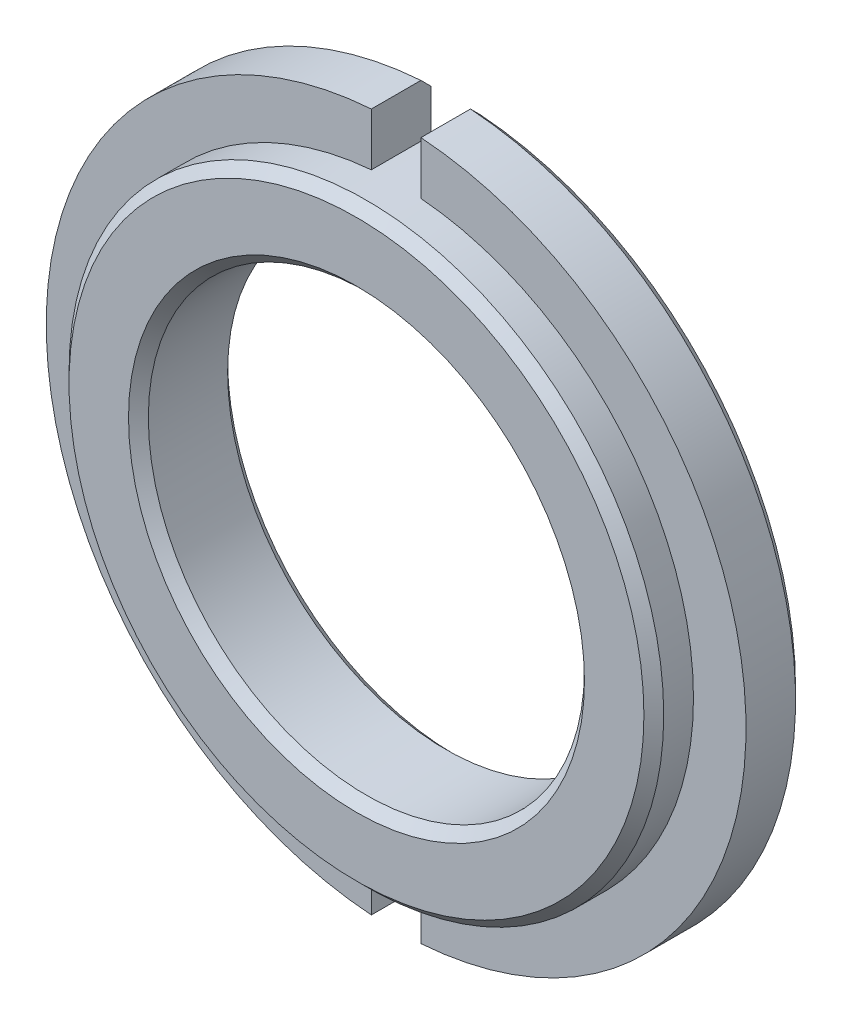
from build123d import *

# Parameters (mm, degrees)
SKETCH1_R           = 17.65
SKETCH1_R_2         = 11
BOSS_EXTRUDE1_DEPTH = 5
SKETCH2_R           = 17.65
SKETCH2_R_2         = 15
CUT_EXTRUDE1_DEPTH  = 2
CUT_EXTRUDE3_REACH  = 5
CHAMFER1_SIZE       = 0.5


with BuildPart() as part:
    # Sketch1 → Boss-Extrude1 (new body)
    with BuildSketch(Plane.XY):
        Circle(SKETCH1_R)
        Circle(SKETCH1_R_2, mode=Mode.SUBTRACT)
    extrude(amount=BOSS_EXTRUDE1_DEPTH)

    # Sketch2 → Cut-Extrude1 (cut)
    with BuildSketch(Plane.XY.offset(5)):
        Circle(SKETCH2_R)
        Circle(SKETCH2_R_2, mode=Mode.SUBTRACT)
    extrude(amount=-CUT_EXTRUDE1_DEPTH, mode=Mode.SUBTRACT)

    # Sketch3 → Cut-Extrude3 (cut, up to next)
    with BuildSketch(Plane.XY.offset(3), mode=Mode.PRIVATE) as cut_extrude3_sk1:
        with BuildLine():
            Line((1.25, 17.605680901), (1.25, 14.947825929))
            ThreePointArc((1.25, 14.947825929), (0, 15), (-1.25, 14.947825929))
            Line((-1.25, 14.947825929), (-1.25, 17.605680901))
            ThreePointArc((-1.25, 17.605680901), (0, 17.65), (1.25, 17.605680901))
        make_face()
    cut_extrude3_tool1 = extrude(cut_extrude3_sk1.sketch, amount=-CUT_EXTRUDE3_REACH, mode=Mode.PRIVATE) & part.part
    add(cut_extrude3_tool1.solids().sort_by_distance((0, 16.308915, 3))[0], mode=Mode.SUBTRACT)
    # Sketch3 → Cut-Extrude3 (cut, up to next)
    with BuildSketch(Plane.XY.offset(3), mode=Mode.PRIVATE) as cut_extrude3_sk2:
        with BuildLine():
            Line((1.25, -14.947825929), (1.25, -17.605680901))
            ThreePointArc((1.25, -17.605680901), (0, -17.65), (-1.25, -17.605680901))
            Line((-1.25, -17.605680901), (-1.25, -14.947825929))
            ThreePointArc((-1.25, -14.947825929), (0, -15), (1.25, -14.947825929))
        make_face()
    cut_extrude3_tool2 = extrude(cut_extrude3_sk2.sketch, amount=-CUT_EXTRUDE3_REACH, mode=Mode.PRIVATE) & part.part
    add(cut_extrude3_tool2.solids().sort_by_distance((0, -16.308915, 3))[0], mode=Mode.SUBTRACT)

    # Chamfer1
    chamfer1_edges = [part.edges().sort_by_distance(p)[0] for p in [
        (-15, 0, 5),
        (-17.65, 0, 0),
        (17.65, 0, 0),
        (-11, 0, 0),
        (-11, 0, 5),
    ]]
    chamfer(chamfer1_edges, length=CHAMFER1_SIZE)


solid = part.part
